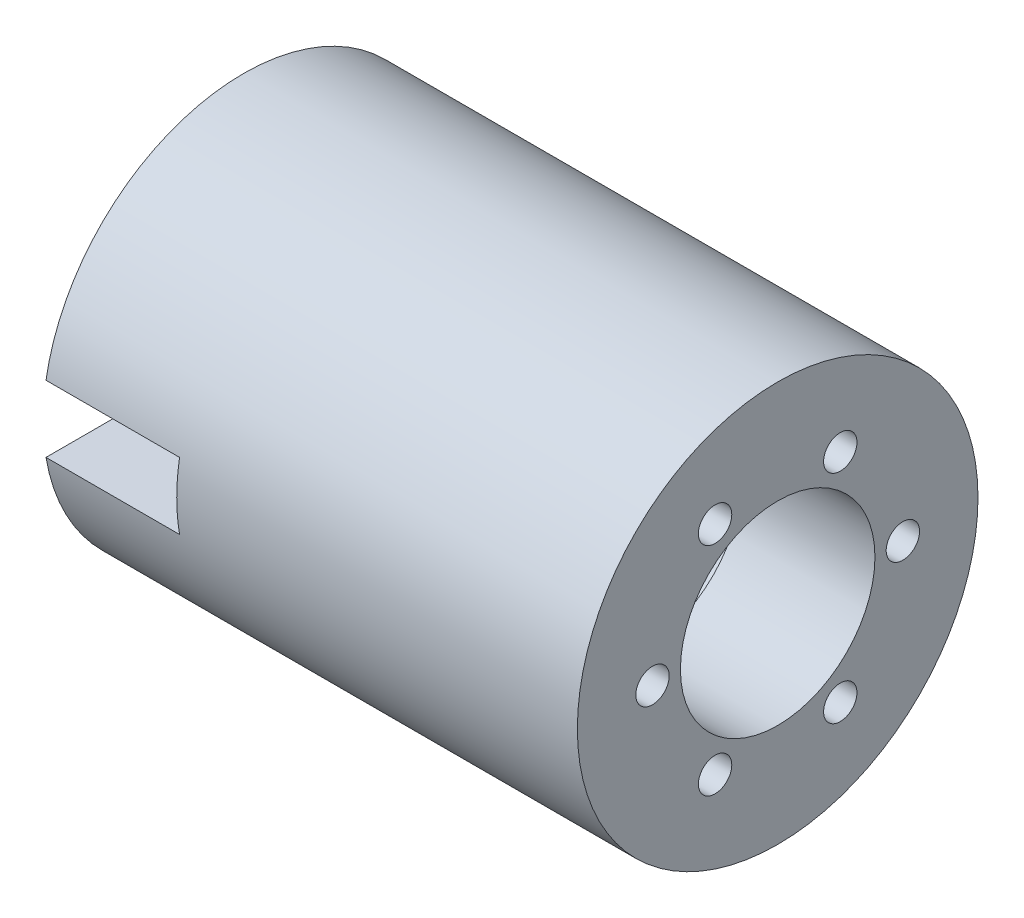
from build123d import *

# Parameters (mm, degrees)
SKETCH1_W          = 25.4
SKETCH1_H          = 5.3975
SKETCH2_R          = 3.175
SKETCH2_R_2        = 18.5
CUT_EXTRUDE1_DEPTH = 25.4
CIRPATTERN1_COUNT  = 6
SKETCH3_W          = 25.4
SKETCH3_H          = 12.7
CUT_EXTRUDE2_DEPTH = 39.1


with BuildPart() as part:
    # Sketch1 → Revolve1 (revolve)
    with BuildSketch(Plane.XY):
        Polygon((-50.8, 38.1), (-50.8, 21.2725), (25.4, 21.2725), (50.8, 21.2725), (50.8, 38.1), (44.45, 38.1), align=None)
        with Locations((38.1, 18.57375)):
            Rectangle(SKETCH1_W, SKETCH1_H)
    revolve(axis=Axis((-50.8, 0, 0), (1, 0, 0)))

    # Sketch2 → Cut-Extrude1 (cut)
    with BuildSketch(Plane(origin=(50.8, 0, 0), x_dir=(0, 0, -1), z_dir=(1, 0, 0))):
        with Locations((-11.90625, -20.622229928)):
            Circle(SKETCH2_R)
        with Locations((11.90625, -20.622229928)):
            Circle(SKETCH2_R)
        with Locations((23.8125, 0)):
            Circle(SKETCH2_R)
        with Locations((11.90625, 20.622229928)):
            Circle(SKETCH2_R)
        with Locations((-11.90625, 20.622229928)):
            Circle(SKETCH2_R)
        Circle(SKETCH2_R_2)
    cut_extrude1 = extrude(amount=-CUT_EXTRUDE1_DEPTH, mode=Mode.SUBTRACT)

    # CirPattern1: Cut-Extrude1 ×6 about axis
    cirpattern1_axis = Axis((-50.8, 0, 0), (-1, 0, 0))
    for i in range(1, CIRPATTERN1_COUNT):
        add(cut_extrude1.rotate(cirpattern1_axis, i * 360 / CIRPATTERN1_COUNT), mode=Mode.SUBTRACT)

    # Sketch3 → Cut-Extrude2 (cut, through all)
    with BuildSketch(Plane.XY):
        with Locations((-38.1, 0)):
            Rectangle(SKETCH3_W, SKETCH3_H)
    extrude(amount=CUT_EXTRUDE2_DEPTH, mode=Mode.SUBTRACT)


solid = part.part
